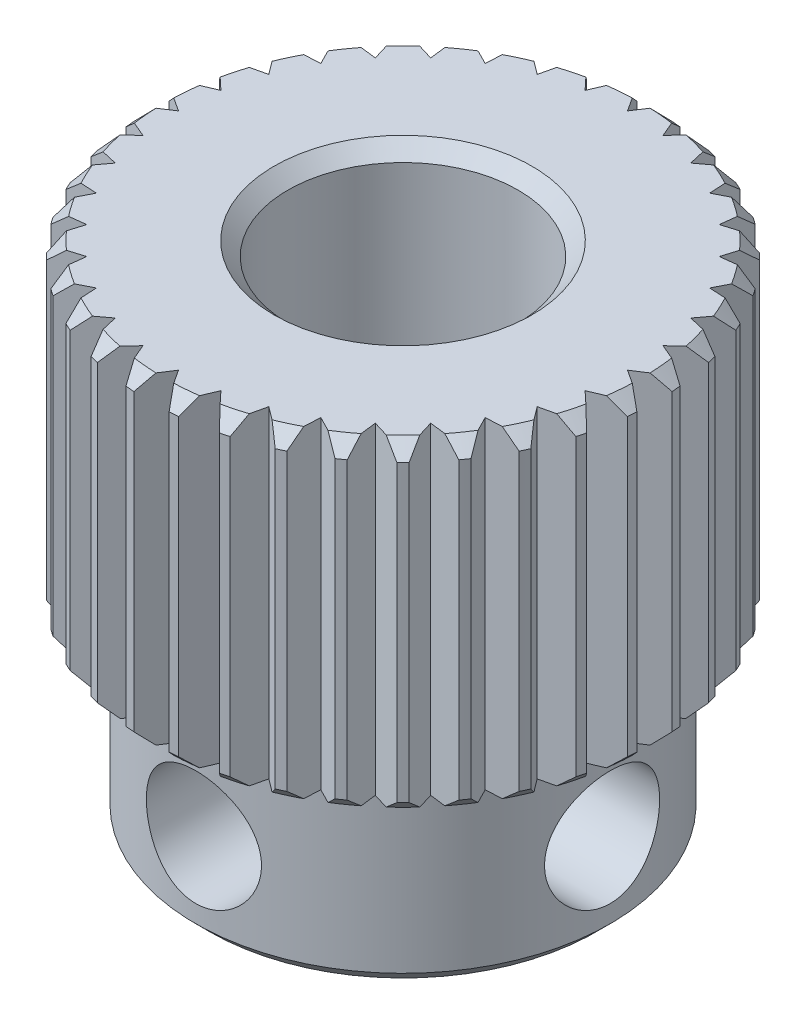
from build123d import *

# Parameters (mm, degrees)
CHAMFER1_SIZE           = 0.3
CUT_EXTRUDE1_DEPTH      = 14.370162677
CIRPATTERN1_COUNT       = 36
CUT_EXTRUDE2_REACH      = 12.697
CUT_EXTRUDE2_END_RADIUS = 4.5
SKETCH5_R               = 1.25
CIRPATTERN2_COUNT       = 2
CIRPATTERN2_ANGLE       = 90


with BuildPart() as part:
    # Sketch1 → Revolve1 (revolve)
    with BuildSketch(Plane.XY, mode=Mode.PRIVATE) as revolve1_sk:
        Polygon((2.5, -7.4), (2.5, 3.5), (5.475, 3.5), (5.475, -3.5), (4.5, -3.5), (4.5, -7.4), align=None)
    revolve(revolve1_sk.sketch.rotate(Axis((0, 0, 0), (0, 1, 0)), 90), axis=Axis((0, 0, 0), (0, 1, 0)))

    # Chamfer1
    chamfer1_edges = [part.edges().sort_by_distance(p)[0] for p in [
        (0, -7.4, 4.5),
        (0, -3.5, 5.475),
        (0, 3.5, 5.475),
        (0, 3.5, 2.5),
        (0, -7.4, 2.5),
    ]]
    chamfer(chamfer1_edges, length=CHAMFER1_SIZE)

    # Sketch4 → Cut-Extrude1 (cut, through all)
    with BuildSketch(Plane(origin=(0, 3.5, 0), x_dir=(1, 0, 0), z_dir=(0, 1, 0))):
        with BuildLine():
            Line((-0.381916694, 5.461663175), (0, 4.875))
            Line((0, 4.875), (0.381916694, 5.461663175))
            ThreePointArc((0.381916694, 5.461663175), (0, 5.475), (-0.381916694, 5.461663175))
        make_face()
    cut_extrude1 = extrude(amount=-CUT_EXTRUDE1_DEPTH, mode=Mode.SUBTRACT)

    # CirPattern1: Cut-Extrude1 ×36 about axis
    cirpattern1_axis = Axis((0, 0, 0), (0, 1, 0))
    for i in range(1, CIRPATTERN1_COUNT):
        add(cut_extrude1.rotate(cirpattern1_axis, i * 360 / CIRPATTERN1_COUNT), mode=Mode.SUBTRACT)

    # Cut-Extrude2: up to this cylinder (the profile starts inside it)
    cut_extrude2_end = Plane(origin=(0, -5.47, 0), z_dir=(0, -1, 0)) * Cylinder(CUT_EXTRUDE2_END_RADIUS, 35.394, mode=Mode.PRIVATE)
    # Sketch5 → Cut-Extrude2 (cut, up to the surface)
    with BuildSketch(Plane.XY, mode=Mode.PRIVATE) as cut_extrude2_sk1:
        with Locations(Location((0, -5.47, 0), (0, 0, 180))):
            Circle(SKETCH5_R)
    cut_extrude2_tool1 = extrude(cut_extrude2_sk1.sketch, amount=CUT_EXTRUDE2_REACH, mode=Mode.PRIVATE) & cut_extrude2_end
    cut_extrude2 = cut_extrude2_tool1.solids().sort_by_distance((0, -5.47, 0))[0]
    add(cut_extrude2, mode=Mode.SUBTRACT)

    # CirPattern2: Cut-Extrude2 ×2 about axis
    cirpattern2_axis = Axis((0, 0, 0), (0, 1, 0))
    for i in range(1, CIRPATTERN2_COUNT):
        add(cut_extrude2.rotate(cirpattern2_axis, i * CIRPATTERN2_ANGLE / (CIRPATTERN2_COUNT - 1)), mode=Mode.SUBTRACT)


solid = part.part
